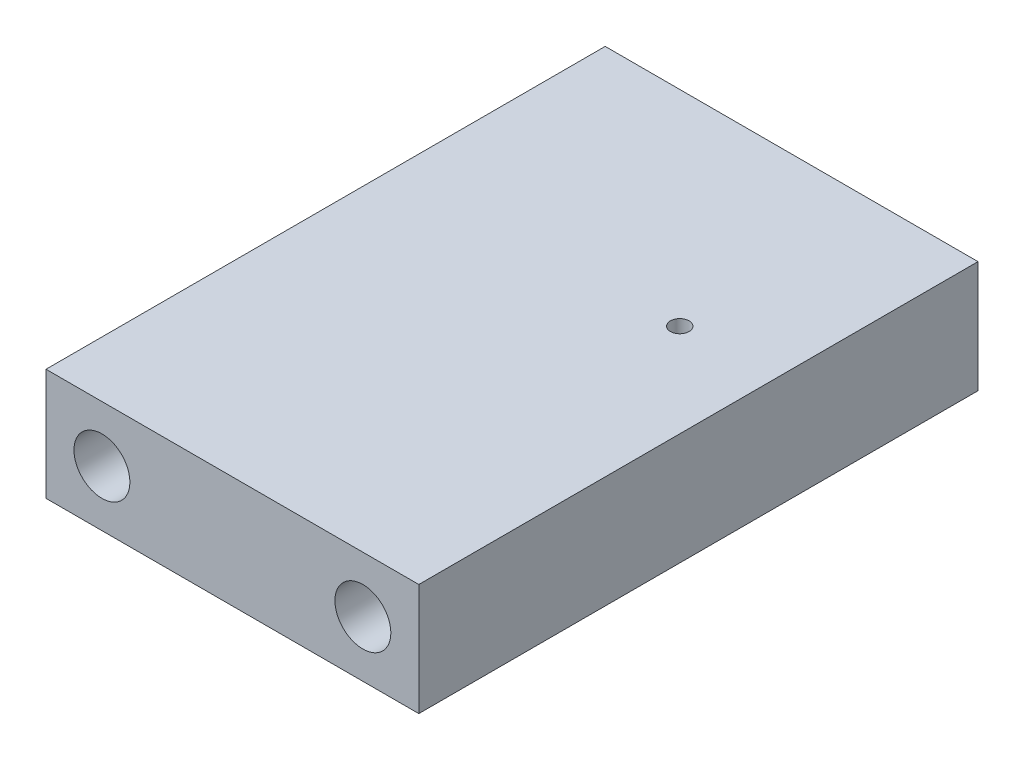
from build123d import *

# Parameters (mm, degrees)
CROQUIS1_W              = 20
CROQUIS1_H              = 6
SALIENTE_EXTRUIR1_DEPTH = 30
CROQUIS2_R              = 1.5
CORTAR_EXTRUIR1_DEPTH   = 5
CROQUIS3_R              = 1.5
CORTAR_EXTRUIR3_DEPTH   = 5
CROQUIS4_R              = 0.5
CORTAR_EXTRUIR4_DEPTH   = 10


with BuildPart() as part:
    # Croquis1 → Saliente-Extruir1 (new body)
    with BuildSketch(Plane.XY):
        with Locations((10, 3)):
            Rectangle(CROQUIS1_W, CROQUIS1_H)
    extrude(amount=SALIENTE_EXTRUIR1_DEPTH)

    # Croquis2 → Cortar-Extruir1 (cut)
    with BuildSketch(Plane.XY.offset(30)):
        with Locations((3, 3)):
            Circle(CROQUIS2_R)
        with Locations((17, 3)):
            Circle(CROQUIS2_R)
    extrude(amount=-CORTAR_EXTRUIR1_DEPTH, mode=Mode.SUBTRACT)

    # Croquis3 → Cortar-Extruir3 (cut)
    with BuildSketch(Plane(origin=(0, 0, 0), x_dir=(-1, 0, 0), z_dir=(0, 0, -1))):
        with Locations((-17, 3)):
            Circle(CROQUIS3_R)
        with Locations((-3, 3)):
            Circle(CROQUIS3_R)
    extrude(amount=-CORTAR_EXTRUIR3_DEPTH, mode=Mode.SUBTRACT)

    # Croquis4 → Cortar-Extruir4 (cut)
    with BuildSketch(Plane(origin=(0, 6, 0), x_dir=(1, 0, 0), z_dir=(0, 1, 0))):
        with Locations((15, -11)):
            Circle(CROQUIS4_R)
    extrude(amount=-CORTAR_EXTRUIR4_DEPTH, mode=Mode.SUBTRACT)


solid = part.part
